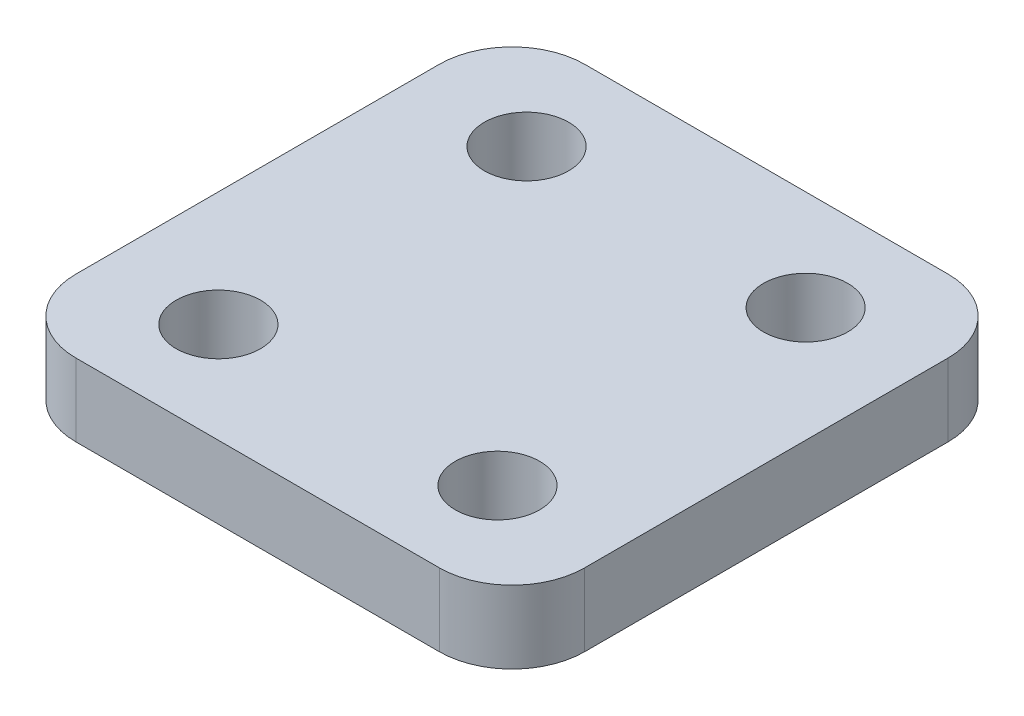
from build123d import *

# Parameters (mm, degrees)
SKETCH1_W           = 17.78
SKETCH1_H           = 17.78
BOSS_EXTRUDE1_DEPTH = 2.54
SKETCH2_R           = 1.4732
CUT_EXTRUDE1_DEPTH  = 3.54
FILLET1_R           = 2.54


with BuildPart() as part:
    # Sketch1 → Boss-Extrude1 (new body)
    with BuildSketch(Plane(origin=(0, 0, 0), x_dir=(1, 0, 0), z_dir=(0, 1, 0))):
        Rectangle(SKETCH1_W, SKETCH1_H)
    extrude(amount=BOSS_EXTRUDE1_DEPTH)

    # Sketch2 → Cut-Extrude1 (cut, through all)
    with BuildSketch(Plane(origin=(0, 2.54, 0), x_dir=(1, 0, 0), z_dir=(0, 1, 0))):
        with Locations((-4.8768, 5.3848)):
            Circle(SKETCH2_R)
        with Locations((-4.8768, -5.3848)):
            Circle(SKETCH2_R)
        with Locations((4.8768, -5.3848)):
            Circle(SKETCH2_R)
        with Locations((4.8768, 5.3848)):
            Circle(SKETCH2_R)
    extrude(amount=-CUT_EXTRUDE1_DEPTH, mode=Mode.SUBTRACT)

    # Fillet1
    fillet1_edges = [part.edges().sort_by_distance(p)[0] for p in [
        (8.89, 1.27, 8.89),
        (-8.89, 1.27, 8.89),
        (-8.89, 1.27, -8.89),
        (8.89, 1.27, -8.89),
    ]]
    fillet(fillet1_edges, radius=FILLET1_R)


solid = part.part
